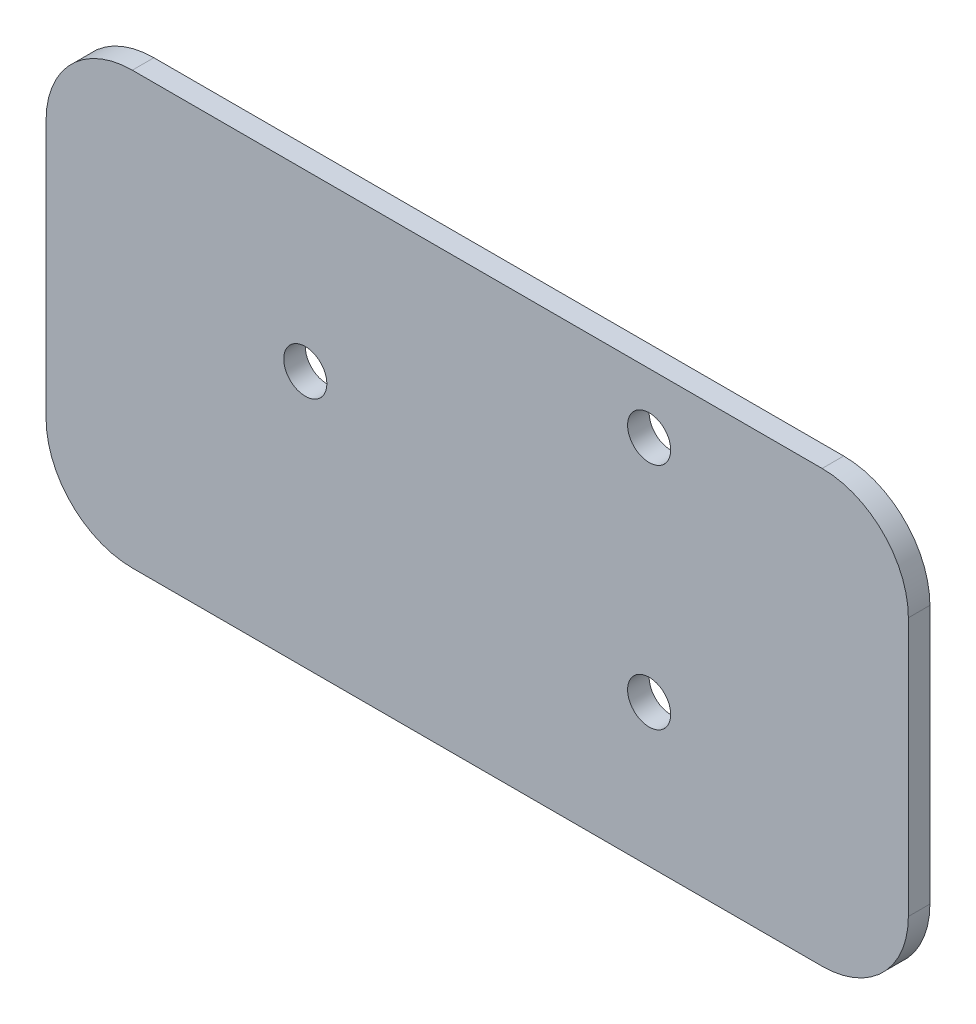
from build123d import *

# Parameters (mm, degrees)
SKETCH1_R           = 3.175
BOSS_EXTRUDE1_DEPTH = 3.175


with BuildPart() as part:
    # Sketch1 → Boss-Extrude1 (new body)
    with BuildSketch(Plane.XY):
        with BuildLine():
            Line((409.779351392, 139.055716341), (511.379351392, 139.055716341))
            ThreePointArc((511.379351392, 139.055716341), (520.359607513, 135.335972462), (524.079351392, 126.355716341))
            Line((524.079351392, 126.355716341), (524.079351392, 88.255716341))
            ThreePointArc((524.079351392, 88.255716341), (520.359607513, 79.27546022), (511.379351392, 75.555716341))
            Line((511.379351392, 75.555716341), (409.779351392, 75.555716341))
            ThreePointArc((409.779351392, 75.555716341), (400.799095271, 79.27546022), (397.079351392, 88.255716341))
            Line((397.079351392, 88.255716341), (397.079351392, 126.355716341))
            ThreePointArc((397.079351392, 126.355716341), (400.799095271, 135.335972462), (409.779351392, 139.055716341))
        make_face()
        with Locations((485.903167936, 130.247970855)):
            Circle(SKETCH1_R, mode=Mode.SUBTRACT)
        with Locations((485.903167936, 96.510716341)):
            Circle(SKETCH1_R, mode=Mode.SUBTRACT)
        with Locations((435.255534848, 113.379343598)):
            Circle(SKETCH1_R, mode=Mode.SUBTRACT)
    extrude(amount=BOSS_EXTRUDE1_DEPTH)


solid = part.part
